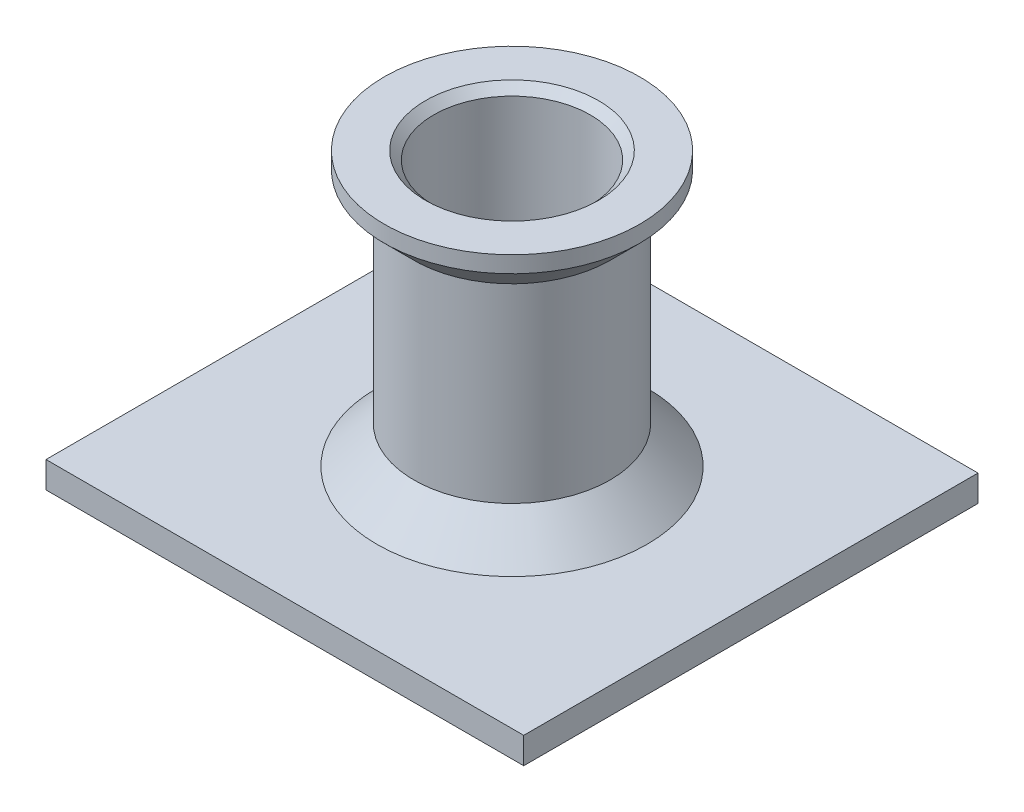
from build123d import *

# Parameters (mm, degrees)
SKETCH2_OUTSIDE_W       = 53.884
SKETCH2_OUTSIDE_H       = 53.884
SKETCH2_OUTSIDE_W_2     = 28.986815524
SKETCH2_OUTSIDE_H_2     = 27.563826398
CUT_EXTRUDE1_DEPTH      = 11
CUT_EXTRUDE1_DEPTH_BACK = 9.193473012


with BuildPart() as part:
    # Sketch1 → Revolve1 (revolve)
    with BuildSketch(Plane.XY):
        Polygon((4.75, 9.5), (4.75, 0), (3.25, -1.5), (3.25, -8.193473012), (20, -8.193473012), (20, -6.593473012), (8.200842899, -6.593473012), (5.95, -4.342630114), (5.95, 7.2), (7.75, 9), (7.75, 10), (5.25, 10), align=None)
    revolve(axis=Axis((0, -12.923275862, 0), (0, 1, 0)))

    # Sketch2 outside → Cut-Extrude1 (cut, two sides)
    with BuildSketch(Plane(origin=(0, 0, 0), x_dir=(1, 0, 0), z_dir=(0, 1, 0))) as cut_extrude1_sk:
        Rectangle(SKETCH2_OUTSIDE_W, SKETCH2_OUTSIDE_H)
        Rectangle(SKETCH2_OUTSIDE_W_2, SKETCH2_OUTSIDE_H_2, mode=Mode.SUBTRACT)
    extrude(amount=CUT_EXTRUDE1_DEPTH, mode=Mode.SUBTRACT)
    extrude(cut_extrude1_sk.sketch, amount=-CUT_EXTRUDE1_DEPTH_BACK, mode=Mode.SUBTRACT)


solid = part.part
